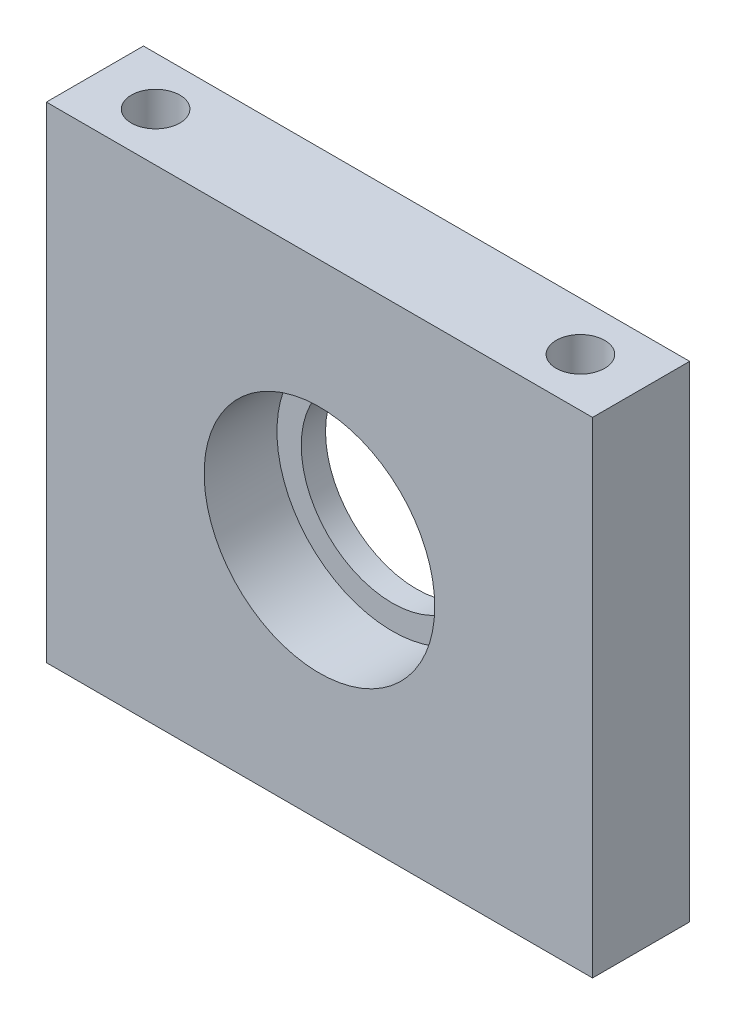
from build123d import *

# Parameters (mm, degrees)
ESQUISSE1_W             = 45
ESQUISSE1_H             = 40
BOSS_EXTRU_1_DEPTH      = 8
ESQUISSE2_R             = 7.5
ENL_V_MAT_EXTRU_1_DEPTH = 9
ESQUISSE3_R             = 9.5
ENL_V_MAT_EXTRU_2_DEPTH = 6
ESQUISSE4_R             = 2
ENL_V_MAT_EXTRU_3_DEPTH = 41


with BuildPart() as part:
    # Esquisse1 → Boss.-Extru.1 (new body)
    with BuildSketch(Plane.XY):
        Rectangle(ESQUISSE1_W, ESQUISSE1_H)
    extrude(amount=BOSS_EXTRU_1_DEPTH)

    # Esquisse2 → Enlèv. mat.-Extru.1 (cut, through all)
    with BuildSketch(Plane.XY.offset(8)):
        Circle(ESQUISSE2_R)
    extrude(amount=-ENL_V_MAT_EXTRU_1_DEPTH, mode=Mode.SUBTRACT)

    # Esquisse3 → Enlèv. mat.-Extru.2 (cut)
    with BuildSketch(Plane.XY.offset(8)):
        Circle(ESQUISSE3_R)
    extrude(amount=-ENL_V_MAT_EXTRU_2_DEPTH, mode=Mode.SUBTRACT)

    # Esquisse4 → Enlèv. mat.-Extru.3 (cut, through all)
    with BuildSketch(Plane(origin=(0, 20, 0), x_dir=(1, 0, 0), z_dir=(0, 1, 0))):
        with Locations((-17.5, -4)):
            Circle(ESQUISSE4_R)
        with Locations((17.5, -4)):
            Circle(ESQUISSE4_R)
    extrude(amount=-ENL_V_MAT_EXTRU_3_DEPTH, mode=Mode.SUBTRACT)


solid = part.part
